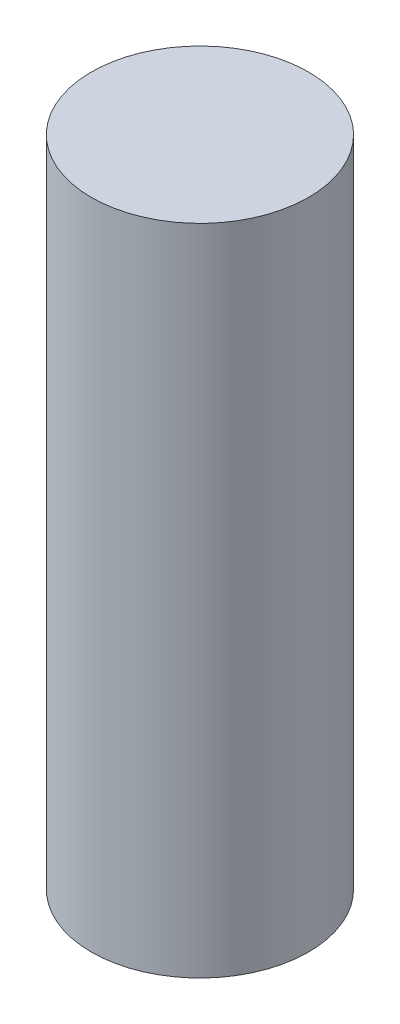
from build123d import *

# Parameters (mm, degrees)
SKETCH1_W = 0.79375
SKETCH1_H = 4.7752


with BuildPart() as part:
    # Sketch1 → Revolve1 (revolve)
    with BuildSketch(Plane(origin=(0, 0, 0), x_dir=(0, 0, -1), z_dir=(1, 0, 0)), mode=Mode.PRIVATE) as revolve1_sk:
        with Locations((0.396875, 2.3876)):
            Rectangle(SKETCH1_W, SKETCH1_H)
    revolve(revolve1_sk.sketch.rotate(Axis((0, 48.626272796, 0), (0, -1, 0)), 180), axis=Axis((0, 48.626272796, 0), (0, -1, 0)))  # turned: the seam where the file's is


solid = part.part
